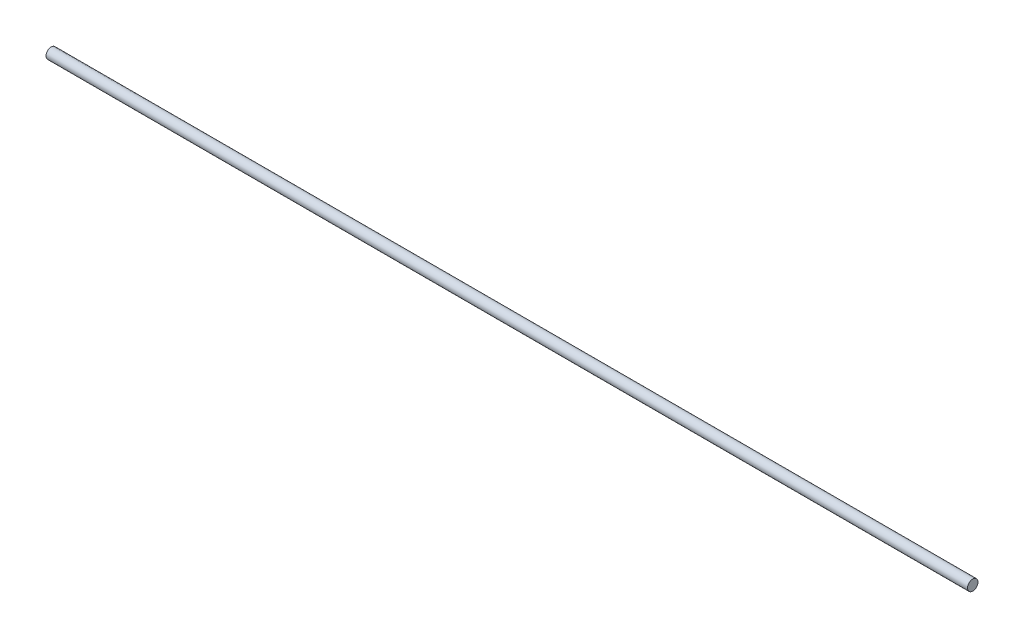
from build123d import *

# Parameters (mm, degrees)
SKETCH1_R           = 5
BOSS_EXTRUDE1_DEPTH = 880


with BuildPart() as part:
    # Sketch1 → Boss-Extrude1 (new body)
    with BuildSketch(Plane(origin=(0, 0, 0), x_dir=(0, 0, -1), z_dir=(1, 0, 0))):
        Circle(SKETCH1_R)
    extrude(amount=BOSS_EXTRUDE1_DEPTH)


solid = part.part
